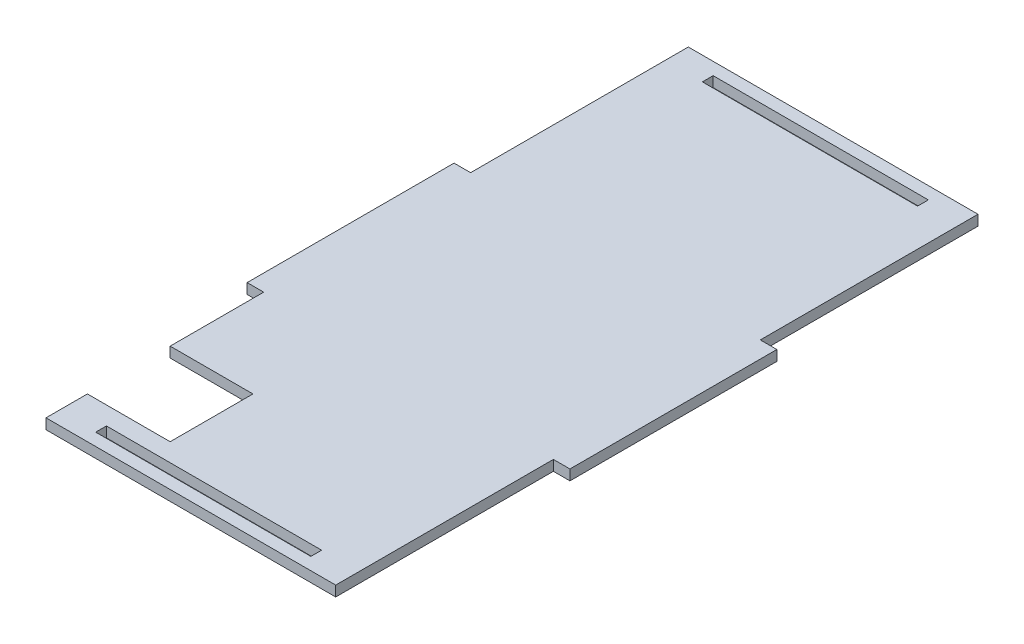
from build123d import *

# Parameters (mm, degrees)
SKETCH2_W           = 52
SKETCH2_H           = 2.6
BOSS_EXTRUDE1_DEPTH = 2.5


with BuildPart() as part:
    # Sketch2 → Boss-Extrude1 (new body)
    with BuildSketch(Plane(origin=(0, 0, 0), x_dir=(1, 0, 0), z_dir=(0, 1, 0))):
        Polygon((35, 25), (35, 77.6), (-35, 77.6), (-35, 25), (-39, 25), (-39, -25), (-35, -25), (-35, -47.6), (-15, -47.6), (-15, -67.6), (-35, -67.6), (-35, -77.6), (35, -77.6), (35, -25), (39, -25), (39, 25), align=None)
        with Locations((0, 73.3)):
            Rectangle(SKETCH2_W, SKETCH2_H, mode=Mode.SUBTRACT)
        with Locations((0, -73.3)):
            Rectangle(SKETCH2_W, SKETCH2_H, mode=Mode.SUBTRACT)
    extrude(amount=BOSS_EXTRUDE1_DEPTH)


solid = part.part
